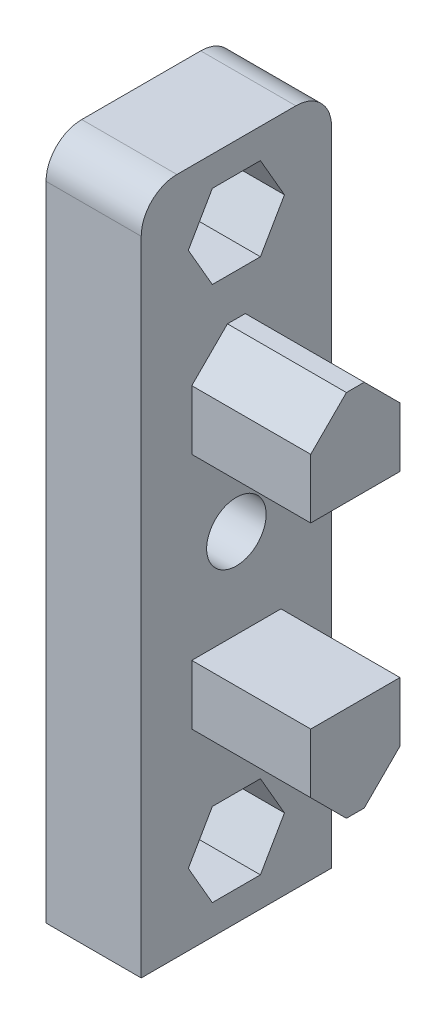
from build123d import *

# Parameters (mm, degrees)
ESQUISSE1_W             = 16
ESQUISSE1_H             = 28.5
BOSS_EXTRU_1_DEPTH      = 8
ENL_V_MAT_EXTRU_1_DEPTH = 5.5
ESQUISSE3_R             = 2.5
ENL_V_MAT_EXTRU_2_DEPTH = 3.5
ESQUISSE4_W             = 7.5
ESQUISSE4_H             = 8
BOSS_EXTRU_2_DEPTH      = 10
CHANFREIN2_SIZE         = 3
ESQUISSE5_R             = 2.5
ENL_V_MAT_EXTRU_3_DEPTH = 9
CONG_1_R                = 3


with BuildPart() as part:
    # Esquisse1 → Boss.-Extru.1 (new body)
    with BuildSketch(Plane(origin=(0, 0, 0), x_dir=(0, 0, -1), z_dir=(1, 0, 0))):
        Rectangle(ESQUISSE1_W, ESQUISSE1_H)
    extrude(amount=BOSS_EXTRU_1_DEPTH)

    # Esquisse2 → Enlèv. mat.-Extru.1 (cut)
    with BuildSketch(Plane(origin=(8, 0, 0), x_dir=(0, 0, -1), z_dir=(1, 0, 0))):
        Polygon((4.041451884, 8.25), (2.020725942, 11.75), (-2.020725942, 11.75), (-4.041451884, 8.25), (-2.020725942, 4.75), (2.020725942, 4.75), align=None)
    extrude(amount=-ENL_V_MAT_EXTRU_1_DEPTH, mode=Mode.SUBTRACT)

    # Esquisse3 → Enlèv. mat.-Extru.2 (cut, through all)
    with BuildSketch(Plane(origin=(2.5, 0, 0), x_dir=(0, 0, -1), z_dir=(1, 0, 0))):
        with Locations((0, 8.25)):
            Circle(ESQUISSE3_R)
    extrude(amount=-ENL_V_MAT_EXTRU_2_DEPTH, mode=Mode.SUBTRACT)

    # Esquisse4 → Boss.-Extru.2 (add)
    with BuildSketch(Plane(origin=(8, 0, 0), x_dir=(0, 0, -1), z_dir=(1, 0, 0))):
        with Locations((0, -2.75)):
            Rectangle(ESQUISSE4_W, ESQUISSE4_H)
    extrude(amount=BOSS_EXTRU_2_DEPTH)

    # Chanfrein2
    chanfrein2_edges = [part.edges().sort_by_distance(p)[0] for p in [
        (13, 1.25, -3.75),
        (13, 1.25, 3.75),
    ]]
    chamfer(chanfrein2_edges, length=CHANFREIN2_SIZE)

    # Symétrie1: part across plane


with BuildPart() as part_1:
    add(part.part)
    add(part.part.mirror(Plane(origin=(8, -14.25, 8), x_dir=(0, 0, 1), z_dir=(0, 1, 0))))

    # Esquisse5 → Enlèv. mat.-Extru.3 (cut, through all)
    with BuildSketch(Plane(origin=(8, 0, 0), x_dir=(0, 0, -1), z_dir=(1, 0, 0))):
        with Locations((0, -14.25)):
            Circle(ESQUISSE5_R)
    extrude(amount=-ENL_V_MAT_EXTRU_3_DEPTH, mode=Mode.SUBTRACT)

    # Congé1
    cong_1_edges = [part_1.edges().sort_by_distance(p)[0] for p in [
        (4, 14.25, 8),
        (4, 14.25, -8),
    ]]
    fillet(cong_1_edges, radius=CONG_1_R)


solid = part_1.part
